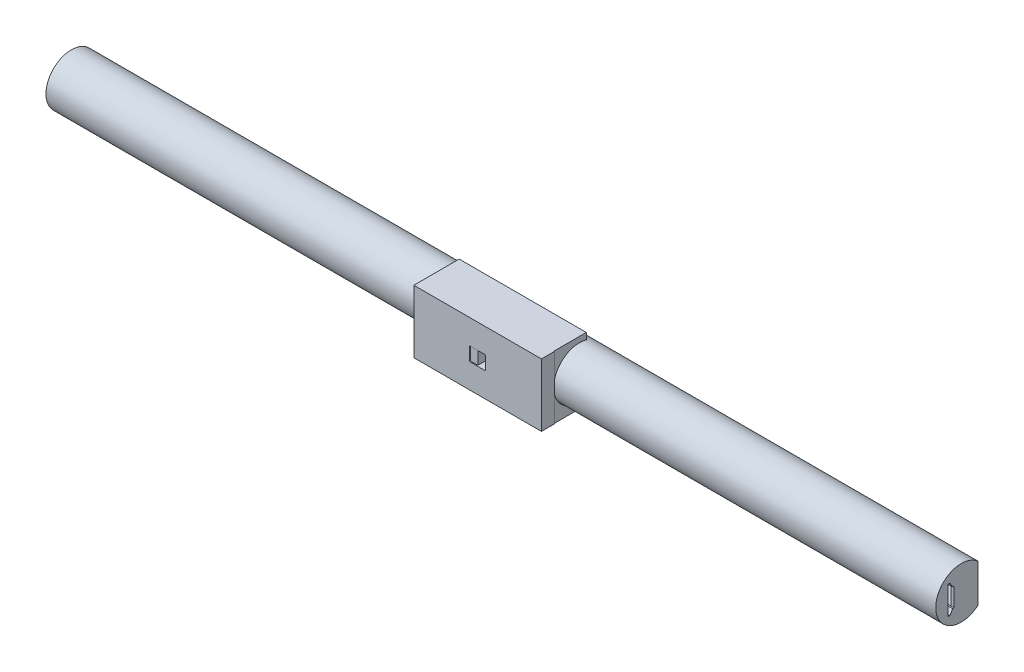
from build123d import *

# Parameters (mm, degrees)
BAR_DEPTH                = 175
SKETCH13_W               = 1.2
SKETCH13_H               = 15
SKETCH13_W_2             = 0.8
BOSS_EXTRUDE1_DEPTH      = 9.375645
SKETCH14_W               = 0.2
SKETCH14_H               = 16.614378278
CUT_EXTRUDE1_DEPTH       = 11
CUT_EXTRUDE1_DEPTH_BACK  = 11
BOSS_EXTRUDE2_DEPTH      = 2.5
BOSS_EXTRUDE3_DEPTH      = 25
BOSS_EXTRUDE3_2_DEPTH    = 25
BOSS_EXTRUDE4_DEPTH      = 12.352443
BOSS_EXTRUDE4_DEPTH_BACK = 12.352443
SKETCH18_W               = 1.2
SKETCH18_H               = 15
BOSS_EXTRUDE5_DEPTH      = 0.2


with BuildPart() as part:
    # Sketch1 → Bar (new body, symmetric)
    with BuildSketch(Plane(origin=(0, 0, 0), x_dir=(0, 0, -1), z_dir=(1, 0, 0))):
        with BuildLine():
            Line((-5.198979486, 5.5), (-4.398979486, 5.5))
            Line((-4.398979486, 5.5), (-3.361266245, 3.702627944))
            Line((-3.361266245, 3.702627944), (-2.761266245, 3.702627944))
            Line((-2.761266245, 3.702627944), (-1.26167279, 6.3))
            Line((-1.26167279, 6.3), (6.614378278, 6.3))
            Line((6.614378278, 6.3), (6.614378278, 7.5))
            ThreePointArc((6.614378278, 7.5), (-10, 0), (6.614378278, -7.5))
            Line((6.614378278, -7.5), (6.614378278, -6.3))
            Line((6.614378278, -6.3), (-1.26167279, -6.3))
            Line((-1.26167279, -6.3), (-2.761266245, -3.702627944))
            Line((-2.761266245, -3.702627944), (-3.361266245, -3.702627944))
            Line((-3.361266245, -3.702627944), (-4.398979486, -5.5))
            Line((-4.398979486, -5.5), (-5.198979486, -5.5))
            Line((-5.198979486, -5.5), (-5.198979486, 5.5))
        make_face()
    extrude(amount=BAR_DEPTH, both=True)

    # Sketch13 → Boss-Extrude1 (add)
    with BuildSketch(Plane(origin=(0, 0, -6.614378278), x_dir=(-1, 0, 0), z_dir=(0, 0, -1))):
        with Locations((174.4, 0)):
            Rectangle(SKETCH13_W, SKETCH13_H)
        with Locations((125, 0)):
            Rectangle(SKETCH13_W_2, SKETCH13_H)
        with Locations((75, 0)):
            Rectangle(SKETCH13_W_2, SKETCH13_H)
        with Locations((25, 0)):
            Rectangle(SKETCH13_W_2, SKETCH13_H)
        with Locations((-25, 0)):
            Rectangle(SKETCH13_W_2, SKETCH13_H)
        with Locations((-75, 0)):
            Rectangle(SKETCH13_W_2, SKETCH13_H)
        with Locations((-125, 0)):
            Rectangle(SKETCH13_W_2, SKETCH13_H)
        with Locations((-174.4, 0)):
            Rectangle(SKETCH13_W, SKETCH13_H)
    extrude(amount=-BOSS_EXTRUDE1_DEPTH)

    # Sketch14 → Cut-Extrude1 (cut, two sides)
    with BuildSketch(Plane(origin=(0, 0, 0), x_dir=(1, 0, 0), z_dir=(0, 1, 0))) as cut_extrude1_sk:
        with Locations((0, -1.692810861)):
            Rectangle(SKETCH14_W, SKETCH14_H)
    extrude(amount=CUT_EXTRUDE1_DEPTH, mode=Mode.SUBTRACT)
    extrude(cut_extrude1_sk.sketch, amount=-CUT_EXTRUDE1_DEPTH_BACK, mode=Mode.SUBTRACT)

    # Sketch15 → Boss-Extrude2 (add, symmetric)
    with BuildSketch(Plane(origin=(0, 0, 0), x_dir=(1, 0, 0), z_dir=(0, 1, 0))):
        Polygon((-0.1, -8), (-0.1, -15), (-3.1, -15), (-10.1, -8), align=None)
    extrude(amount=BOSS_EXTRUDE2_DEPTH, both=True)

    # Sketch18 → Boss-Extrude5 (add)
    with BuildSketch(Plane(origin=(0, 0, -6.614378278), x_dir=(-1, 0, 0), z_dir=(0, 0, -1))):
        with Locations((0.7, 0)):
            Rectangle(SKETCH18_W, SKETCH18_H)
    extrude(amount=-BOSS_EXTRUDE5_DEPTH)


with BuildPart() as body_2:
    # Sketch16 → Boss-Extrude3 (new body, symmetric)
    with BuildSketch(Plane(origin=(-0.1, 0, 0), x_dir=(0, 0, -1), z_dir=(1, 0, 0))):
        with BuildLine():
            ThreePointArc((-9.836157786, -2.7), (-5.073036373, -8.848971802), (2.63995426, -9.852443428))
            Line((2.63995426, -9.852443428), (2.63995426, -12.352443428))
            Line((2.63995426, -12.352443428), (-15.2, -12.352443428))
            Line((-15.2, -12.352443428), (-15.2, -2.7))
            Line((-15.2, -2.7), (-9.836157786, -2.7))
        make_face()
    extrude(amount=BOSS_EXTRUDE3_DEPTH, both=True)



with BuildPart() as body_3:
    # Sketch16 → Boss-Extrude3 2 (new body, symmetric)
    with BuildSketch(Plane(origin=(-0.1, 0, 0), x_dir=(0, 0, -1), z_dir=(1, 0, 0))):
        with BuildLine():
            Line((-9.836157786, 2.7), (-15.2, 2.7))
            Line((-15.2, 2.7), (-15.2, 12.352443428))
            Line((-15.2, 12.352443428), (2.63995426, 12.352443428))
            Line((2.63995426, 12.352443428), (2.63995426, 9.852443428))
            ThreePointArc((2.63995426, 9.852443428), (-5.073036373, 8.848971802), (-9.836157786, 2.7))
        make_face()
    extrude(amount=BOSS_EXTRUDE3_2_DEPTH, both=True)


with BuildPart() as body_2_1:
    add(body_2.part)

    add(body_3.part)  # Boss-Extrude4 merges body 3
    # Sketch17 → Boss-Extrude4 (add, two sides)
    with BuildSketch(Plane(origin=(0, 0, 0), x_dir=(1, 0, 0), z_dir=(0, 1, 0))) as boss_extrude4_sk:
        Polygon((-25.1, -10.1), (-8.282842712, -10.1), (-3.182842712, -15.2), (-25.1, -15.2), align=None)
        Polygon((8.282842712, -10.1), (25.1, -10.1), (25.1, -15.2), (3.182842712, -15.2), align=None)
    extrude(amount=BOSS_EXTRUDE4_DEPTH)
    extrude(boss_extrude4_sk.sketch, amount=-BOSS_EXTRUDE4_DEPTH_BACK)


solid = Compound([part.part, body_2_1.part])
